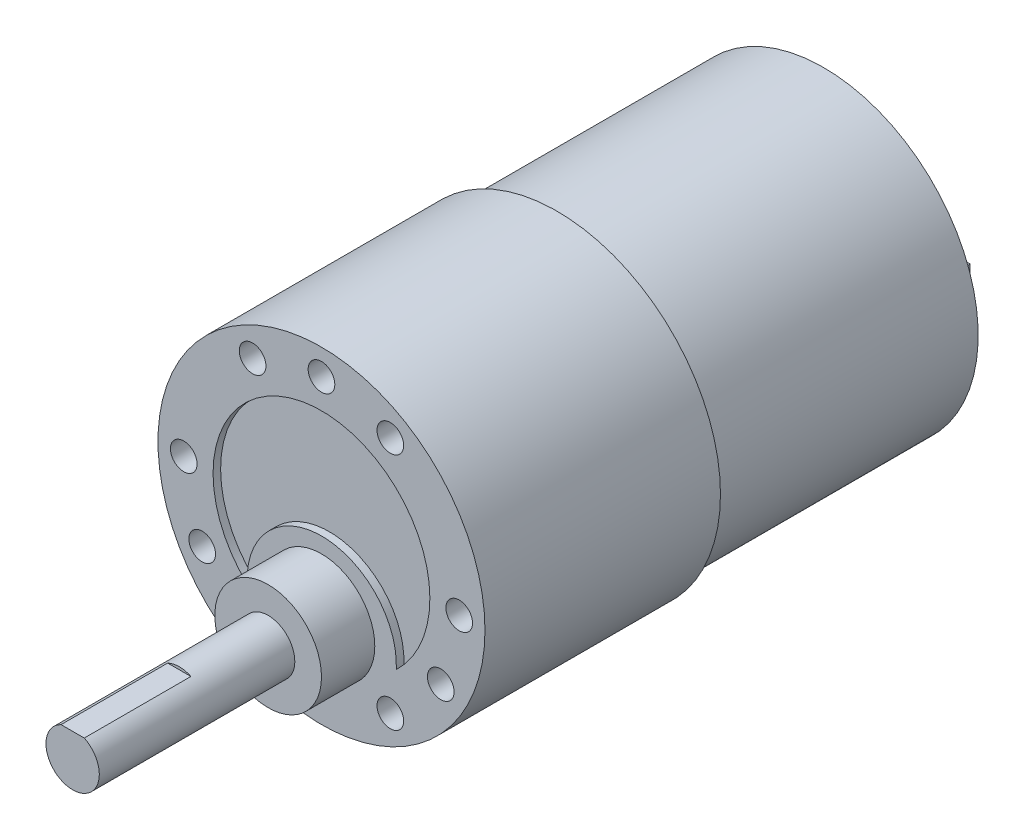
from build123d import *

# Parameters (mm, degrees)
CROQUIS1_R              = 18.4
SALIENTE_EXTRUIR1_DEPTH = 26.5
CORTAR_EXTRUIR2_DEPTH   = 0.85
CROQUIS3_R              = 1.5
CORTAR_EXTRUIR3_DEPTH   = 25
CROQUIS9_R              = 1.5
CORTAR_EXTRUIR4_DEPTH   = 5
CROQUIS22_R             = 6
SALIENTE_EXTRUIR2_DEPTH = 6
CROQUIS24_R             = 3
SALIENTE_EXTRUIR3_DEPTH = 22
CORTAR_EXTRUIR5_DEPTH   = 12
CROQUIS26_R             = 17.4
SALIENTE_EXTRUIR4_DEPTH = 30
CROQUIS27_R             = 3.9
CROQUIS27_R_2           = 2.25
CROQUIS27_W             = 0.5
CROQUIS27_H             = 3
SALIENTE_EXTRUIR5_DEPTH = 1.6
CROQUIS29_W             = 0.5
CROQUIS29_H             = 3
SALIENTE_EXTRUIR6_DEPTH = 5


with BuildPart() as part:
    # Croquis1 → Saliente-Extruir1 (new body)
    with BuildSketch(Plane.XY):
        Circle(CROQUIS1_R)
    extrude(amount=SALIENTE_EXTRUIR1_DEPTH)

    # Croquis2 → Cortar-Extruir2 (cut)
    with BuildSketch(Plane.XY.offset(26.5)):
        with BuildLine():
            ThreePointArc((8.4190219, -8.8295), (-0.043589152, 12.19992213), (-8.355713846, -8.889434523))
            ThreePointArc((-8.355713846, -8.889434523), (0, 0), (8.4190219, -8.8295))
        make_face()
    extrude(amount=-CORTAR_EXTRUIR2_DEPTH, mode=Mode.SUBTRACT)

    # Croquis3 → Cortar-Extruir3 (cut)
    with BuildSketch(Plane.XY.offset(26.5)):
        with Locations((0, 15.5)):
            Circle(CROQUIS3_R)
        with Locations((13.423393759, -7.75)):
            Circle(CROQUIS3_R)
        with Locations((-13.423393759, -7.75)):
            Circle(CROQUIS3_R)
    extrude(amount=-CORTAR_EXTRUIR3_DEPTH, mode=Mode.SUBTRACT)

    # Croquis9 → Cortar-Extruir4 (cut)
    with BuildSketch(Plane.XY.offset(26.5)):
        with Locations((-15.5, 0)):
            Circle(CROQUIS9_R)
        with Locations((-7.75, 13.423393759)):
            Circle(CROQUIS9_R)
        with Locations((7.75, 13.423393759)):
            Circle(CROQUIS9_R)
        with Locations((15.5, 0)):
            Circle(CROQUIS9_R)
        with Locations((7.75, -13.423393759)):
            Circle(CROQUIS9_R)
        with Locations((-7.75, -13.423393759)):
            Circle(CROQUIS9_R)
    extrude(amount=-CORTAR_EXTRUIR4_DEPTH, mode=Mode.SUBTRACT)

    # Croquis22 → Saliente-Extruir2 (add)
    with BuildSketch(Plane.XY.offset(26.5)):
        with Locations((0, -7.75)):
            Circle(CROQUIS22_R)
    extrude(amount=SALIENTE_EXTRUIR2_DEPTH)

    # Croquis24 → Saliente-Extruir3 (add)
    with BuildSketch(Plane.XY.offset(32.5)):
        with Locations((0, -7.75)):
            Circle(CROQUIS24_R)
    extrude(amount=SALIENTE_EXTRUIR3_DEPTH)

    # Croquis25 → Cortar-Extruir5 (cut)
    with BuildSketch(Plane.XY.offset(54.5)):
        Polygon((-72.570863995, -5.05), (-1.307669683, -5.05), (1.307669683, -5.05), (72.570863995, -5.05), (72.570863995, 137.476388625), (-72.570863995, 137.476388625), align=None)
    extrude(amount=-CORTAR_EXTRUIR5_DEPTH, mode=Mode.SUBTRACT)

    # Croquis26 → Saliente-Extruir4 (add)
    with BuildSketch(Plane(origin=(0, 0, 0), x_dir=(-1, 0, 0), z_dir=(0, 0, -1))):
        Circle(CROQUIS26_R)
    extrude(amount=SALIENTE_EXTRUIR4_DEPTH)

    # Croquis27 → Saliente-Extruir5 (add)
    with BuildSketch(Plane(origin=(0, 0, -30), x_dir=(-1, 0, 0), z_dir=(0, 0, -1))):
        Circle(CROQUIS27_R)
        with Locations((-11.25, 0)):
            Circle(CROQUIS27_R_2)
        with Locations((-11.25, 0)):
            Rectangle(CROQUIS27_W, CROQUIS27_H, mode=Mode.SUBTRACT)
        with Locations((11.25, 0)):
            Circle(CROQUIS27_R_2)
        with Locations((11.25, 0)):
            Rectangle(CROQUIS27_W, CROQUIS27_H, mode=Mode.SUBTRACT)
    extrude(amount=SALIENTE_EXTRUIR5_DEPTH)

    # Croquis29 → Saliente-Extruir6 (add)
    with BuildSketch(Plane(origin=(0, 0, -30), x_dir=(-1, 0, 0), z_dir=(0, 0, -1))):
        with Locations((-11.25, 0)):
            Rectangle(CROQUIS29_W, CROQUIS29_H)
        with Locations((11.25, 0)):
            Rectangle(CROQUIS29_W, CROQUIS29_H)
    extrude(amount=SALIENTE_EXTRUIR6_DEPTH)


solid = part.part
